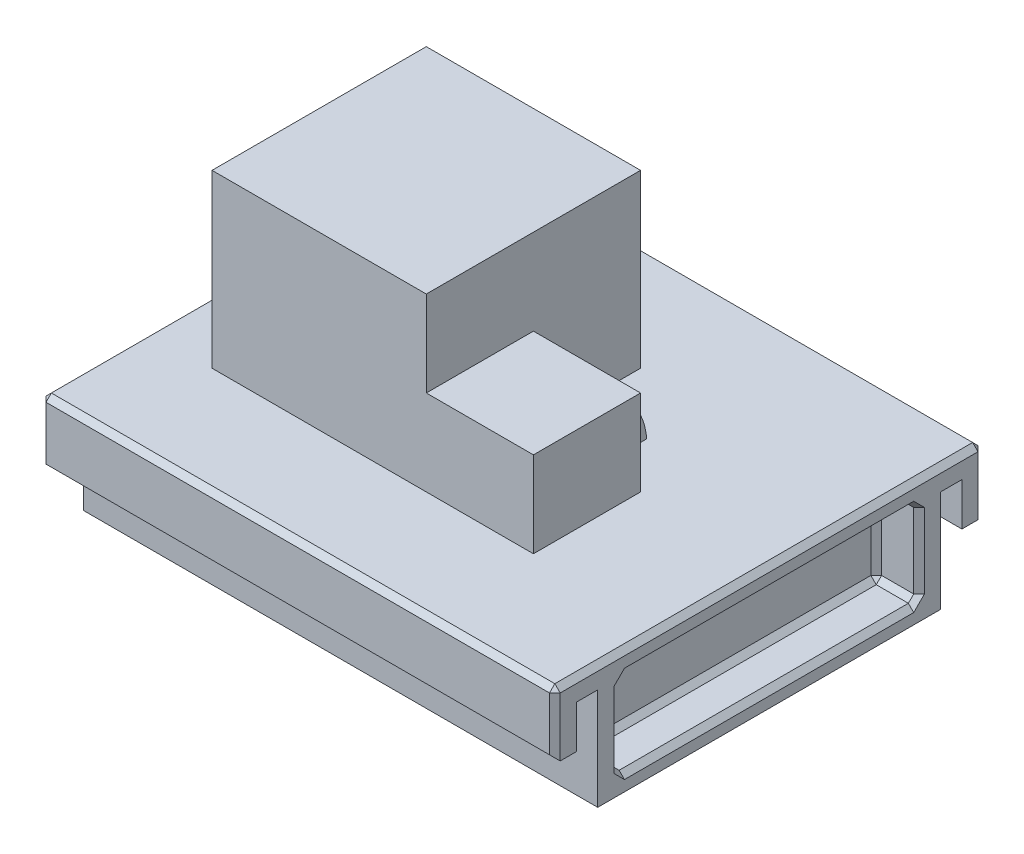
from build123d import *

# Parameters (mm, degrees)
BOSS_EXTRUDE1_DEPTH = 60
SKETCH2_W           = 50
SKETCH2_H           = 50
BOSS_EXTRUDE2_DEPTH = 40
SKETCH2_3_W         = 25
SKETCH2_3_H         = 25
BOSS_EXTRUDE3_DEPTH = 20
SKETCH7_W           = 70
SKETCH7_H           = 20
CUT_EXTRUDE1_DEPTH  = 10
SKETCH8_W           = 10
SKETCH8_H           = 5
BOSS_EXTRUDE4_DEPTH = 5
CHAMFER1_SIZE       = 1.25


with BuildPart() as part:
    # Sketch1 → Boss-Extrude1 (new body, symmetric)
    with BuildSketch(Plane(origin=(0, 0, 0), x_dir=(0, 0, -1), z_dir=(1, 0, 0))):
        Polygon((-40, 0), (-45, 0), (-45, -10), (-50, -10), (-50, 5), (50, 5), (50, -10), (45, -10), (45, 0), (40, 0), (40, -25), (-40, -25), align=None)
    extrude(amount=BOSS_EXTRUDE1_DEPTH, both=True)

    # Sketch2 → Boss-Extrude2 (add)
    with BuildSketch(Plane(origin=(0, 5, 0), x_dir=(1, 0, 0), z_dir=(0, 1, 0))):
        with Locations((-20, 0)):
            Rectangle(SKETCH2_W, SKETCH2_H)
    extrude(amount=BOSS_EXTRUDE2_DEPTH)

    # Sketch2_3 → Boss-Extrude3 (add)
    with BuildSketch(Plane(origin=(0, 5, 0), x_dir=(1, 0, 0), z_dir=(0, 1, 0))):
        with Locations((17.5, -12.5)):
            Rectangle(SKETCH2_3_W, SKETCH2_3_H)
    extrude(amount=BOSS_EXTRUDE3_DEPTH)

    # Sketch3 → Loft3 section 0
    with BuildSketch(Plane(origin=(0, 0, 0), x_dir=(-1, 0, 0), z_dir=(0, 0, -1))):
        Polygon((-17.5, 17.886751346), (-20, 16.443375673), (-20, 13.556624327), (-17.5, 12.113248654), (-15, 13.556624327), (-15, 16.443375673), align=None)
    # Sketch6 → Loft3 section 1
    with BuildSketch(Plane(origin=(0, 2.5, 2.5), x_dir=(1, 0, 0), z_dir=(0, 0.707106781, 0.707106781))):
        Polygon((17.5, 16.422285252), (15, 14.978909579), (15, 12.092158233), (17.5, 10.64878256), (20, 12.092158233), (20, 14.978909579), align=None)
    # Sketch4 → Loft3 section 2
    with BuildSketch(Plane(origin=(0, 5, 0), x_dir=(1, 0, 0), z_dir=(0, 1, 0))):
        Polygon((17.5, 12.886751346), (15, 11.443375673), (15, 8.556624327), (17.5, 7.113248654), (20, 8.556624327), (20, 11.443375673), align=None)
    loft()

    # Sketch7 → Cut-Extrude1 (cut)
    with BuildSketch(Plane(origin=(60, 0, 0), x_dir=(0, 0, -1), z_dir=(1, 0, 0))):
        with Locations((0, -10)):
            Rectangle(SKETCH7_W, SKETCH7_H)
    cut_extrude1 = extrude(amount=-CUT_EXTRUDE1_DEPTH, mode=Mode.SUBTRACT)

    # Mirror1: Cut-Extrude1 across plane
    add(cut_extrude1.mirror(Plane(origin=(0, 0, 0), x_dir=(0, 0, 1), z_dir=(1, 0, 0))), mode=Mode.SUBTRACT)

    # Sketch8 → Boss-Extrude4 (add)
    with BuildSketch(Plane.XZ.offset(25)):
        Rectangle(SKETCH8_W, SKETCH8_H)
    extrude(amount=BOSS_EXTRUDE4_DEPTH)

    # Chamfer1
    chamfer1_edges = [part.edges().sort_by_distance(p)[0] for p in [
        (50, 0, 0),
        (55, 0, 35),
        (50, -10, -35),
        (55, 0, -35),
        (50, -20, 0),
        (55, -20, -35),
        (50, -10, 35),
        (55, -20, 35),
        (60, 0, 0),
        (60, -10, 35),
        (60, -20, 0),
        (60, -10, -35),
        (-60, 0, 0),
        (-55, 0, -35),
        (-60, -2.5, 50),
        (-60, -10, 35),
        (-55, 0, 35),
        (-60, -20, 0),
        (-55, -20, 35),
        (-60, -10, -35),
        (-55, -20, -35),
        (-50, -10, 35),
        (-50, -10, -35),
        (-60, 5, 0),
        (-60, -2.5, -50),
        (-60, -25, 0),
        (0, -10, 50),
        (0, 5, 50),
        (0, 5, -50),
        (0, -10, -50),
        (0, -25, -40),
        (0, -25, 40),
        (60, -2.5, -50),
        (60, 5, 0),
        (60, -2.5, 50),
        (60, -25, 0),
    ]]
    chamfer(chamfer1_edges, length=CHAMFER1_SIZE)


solid = part.part
